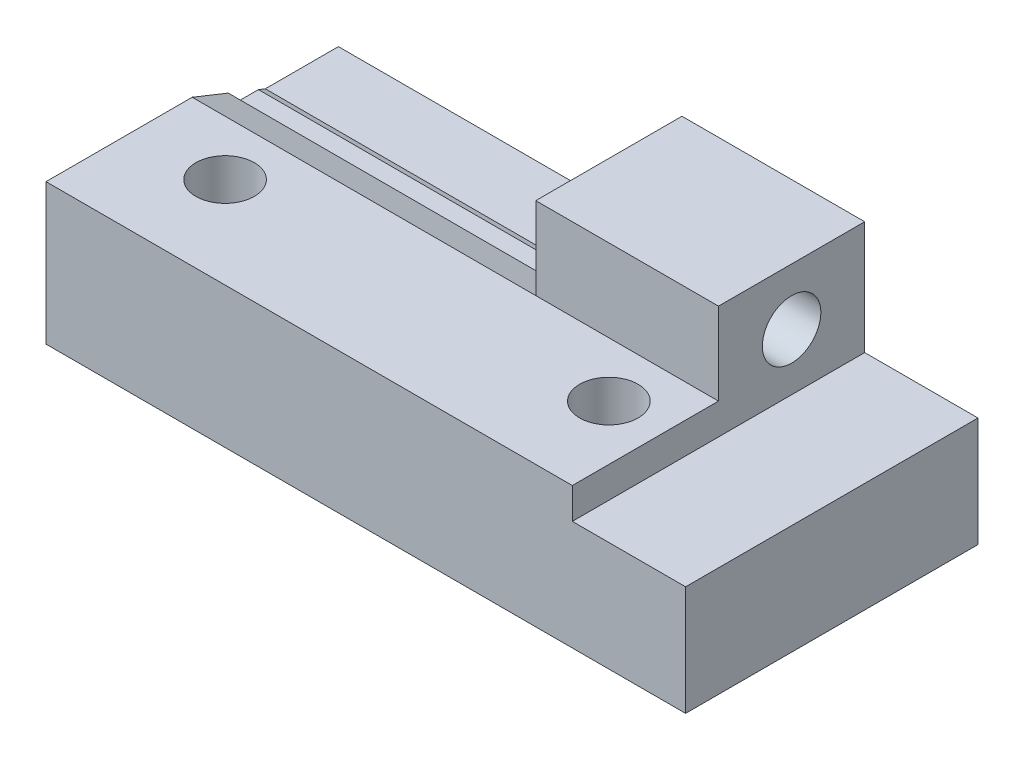
from build123d import *

# Parameters (mm, degrees)
SALIENTE_EXTRUIR1_DEPTH           = 8
SALIENTE_EXTRUIR2_DEPTH           = 8
CORTAR_EXTRUIR1_REACH             = 30.8
CROQUIS3_R                        = 1.6
CORTAR_EXTRUIR2_REACH             = 9.7
CROQUIS4_R                        = 1.6
CORTAR_EXTRUIR3_DEPTH             = 3
CORTAR_EXTRUIR4_DEPTH             = 18.8
CORTAR_EXTRUIR5_DEPTH             = 3
CORTAR_EXTRUIR5_DIRECTION_2_REACH = 20.8


with BuildPart() as part:
    # Croquis1 → Saliente-Extruir1 (new body)
    with BuildSketch(Plane.XY):
        Polygon((0, 0), (0, 6), (-6.2, 6), (-6.2, 12.2), (-35, 12.2), (-35, 0), align=None)
    extrude(amount=SALIENTE_EXTRUIR1_DEPTH)

    # Croquis2 → Saliente-Extruir2 (add)
    with BuildSketch(Plane.XY.offset(8)):
        Polygon((-6.2, 7.7), (-35, 7.7), (-35, 0), (0, 0), (0, 6), (-6.2, 6), align=None)
    extrude(amount=SALIENTE_EXTRUIR2_DEPTH)

    # Croquis3 → Cortar-Extruir1 (cut, up to next)
    with BuildSketch(Plane(origin=(-6.2, 0, 0), x_dir=(0, 0, -1), z_dir=(1, 0, 0)), mode=Mode.PRIVATE) as cortar_extruir1_sk1:
        with Locations((-4, 9.1)):
            Circle(CROQUIS3_R)
    cortar_extruir1_tool1 = extrude(cortar_extruir1_sk1.sketch, amount=-CORTAR_EXTRUIR1_REACH, mode=Mode.PRIVATE) & part.part
    add(cortar_extruir1_tool1.solids().sort_by_distance((-6.2, 9.1, 4))[0], mode=Mode.SUBTRACT)

    # Croquis4 → Cortar-Extruir2 (cut, up to next)
    with BuildSketch(Plane(origin=(0, 7.7, 0), x_dir=(1, 0, 0), z_dir=(0, 1, 0)), mode=Mode.PRIVATE) as cortar_extruir2_sk1:
        with Locations((-30.2, -11)):
            Circle(CROQUIS4_R)
    cortar_extruir2_tool1 = extrude(cortar_extruir2_sk1.sketch, amount=-CORTAR_EXTRUIR2_REACH, mode=Mode.PRIVATE) & part.part
    add(cortar_extruir2_tool1.solids().sort_by_distance((-30.2, 7.7, 11))[0], mode=Mode.SUBTRACT)
    # Croquis4 → Cortar-Extruir2 (cut, up to next)
    with BuildSketch(Plane(origin=(0, 7.7, 0), x_dir=(1, 0, 0), z_dir=(0, 1, 0)), mode=Mode.PRIVATE) as cortar_extruir2_sk2:
        with Locations((-9.2, -11)):
            Circle(CROQUIS4_R)
    cortar_extruir2_tool2 = extrude(cortar_extruir2_sk2.sketch, amount=-CORTAR_EXTRUIR2_REACH, mode=Mode.PRIVATE) & part.part
    add(cortar_extruir2_tool2.solids().sort_by_distance((-9.2, 7.7, 11))[0], mode=Mode.SUBTRACT)

    # Croquis5 → Cortar-Extruir3 (cut)
    with BuildSketch(Plane.XZ):
        Polygon((-33.490896534, 11), (-31.845448267, 8.15), (-28.554551733, 8.15), (-26.909103466, 11), (-28.554551733, 13.85), (-31.845448267, 13.85), align=None)
        Polygon((-12.490896534, 11), (-10.845448267, 8.15), (-7.554551733, 8.15), (-5.909103466, 11), (-7.554551733, 13.85), (-10.845448267, 13.85), align=None)
    extrude(amount=-CORTAR_EXTRUIR3_DEPTH, mode=Mode.SUBTRACT)

    # Croquis6 → Cortar-Extruir4 (cut)
    with BuildSketch(Plane.ZY.offset(35)):
        Polygon((8, 7.7), (4, 6.1), (0, 6.1), (0, 12.2), (8, 12.2), align=None)
    extrude(amount=-CORTAR_EXTRUIR4_DEPTH, mode=Mode.SUBTRACT)

    # Croquis7 → Cortar-Extruir5 (cut)
    with BuildSketch(Plane.ZY.offset(16.2)):
        Polygon((0.709103466, 9.1), (2.354551733, 6.25), (5.645448267, 6.25), (7.290896534, 9.1), (5.645448267, 11.95), (2.354551733, 11.95), align=None)
    extrude(amount=-CORTAR_EXTRUIR5_DEPTH, mode=Mode.SUBTRACT)

    # Croquis7 → Cortar-Extruir5 direction 2 (cut, up to next)
    with BuildSketch(Plane.ZY.offset(16.2), mode=Mode.PRIVATE) as cortar_extruir5_direction_2_sk1:
        Polygon((0.709103466, 9.1), (2.354551733, 6.25), (5.645448267, 6.25), (7.290896534, 9.1), (5.645448267, 11.95), (2.354551733, 11.95), align=None)
    cortar_extruir5_direction_2_tool1 = extrude(cortar_extruir5_direction_2_sk1.sketch, amount=CORTAR_EXTRUIR5_DIRECTION_2_REACH, mode=Mode.PRIVATE) & part.part
    add(cortar_extruir5_direction_2_tool1.solids().sort_by_distance((-16.2, 9.1, 4))[0], mode=Mode.SUBTRACT)


solid = part.part
